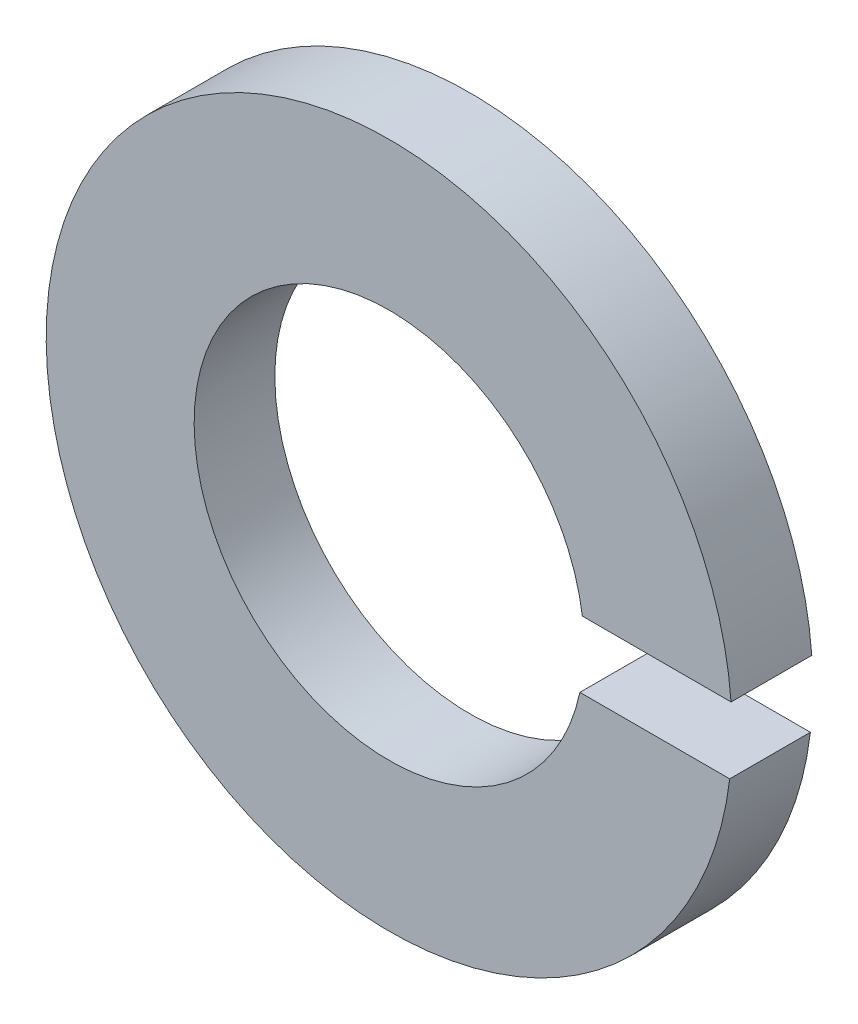
from build123d import *

# Parameters (mm, degrees)
BOSS_EXTRUDE1_DEPTH = 0.6


with BuildPart() as part:
    # Sketch1 → Boss-Extrude1 (new body)
    with BuildSketch(Plane.XY):
        with BuildLine():
            ThreePointArc((2.542318495, 0.197779353), (-2.549460046, 0.052473543), (2.532027385, -0.302220647))
            Line((2.532027385, -0.302220647), (1.418154674, -0.302220647))
            ThreePointArc((1.418154674, -0.302220647), (-1.449030483, 0.053015648), (1.436448164, 0.197779353))
            Line((1.436448164, 0.197779353), (2.542318495, 0.197779353))
        make_face()
    extrude(amount=BOSS_EXTRUDE1_DEPTH)


solid = part.part
